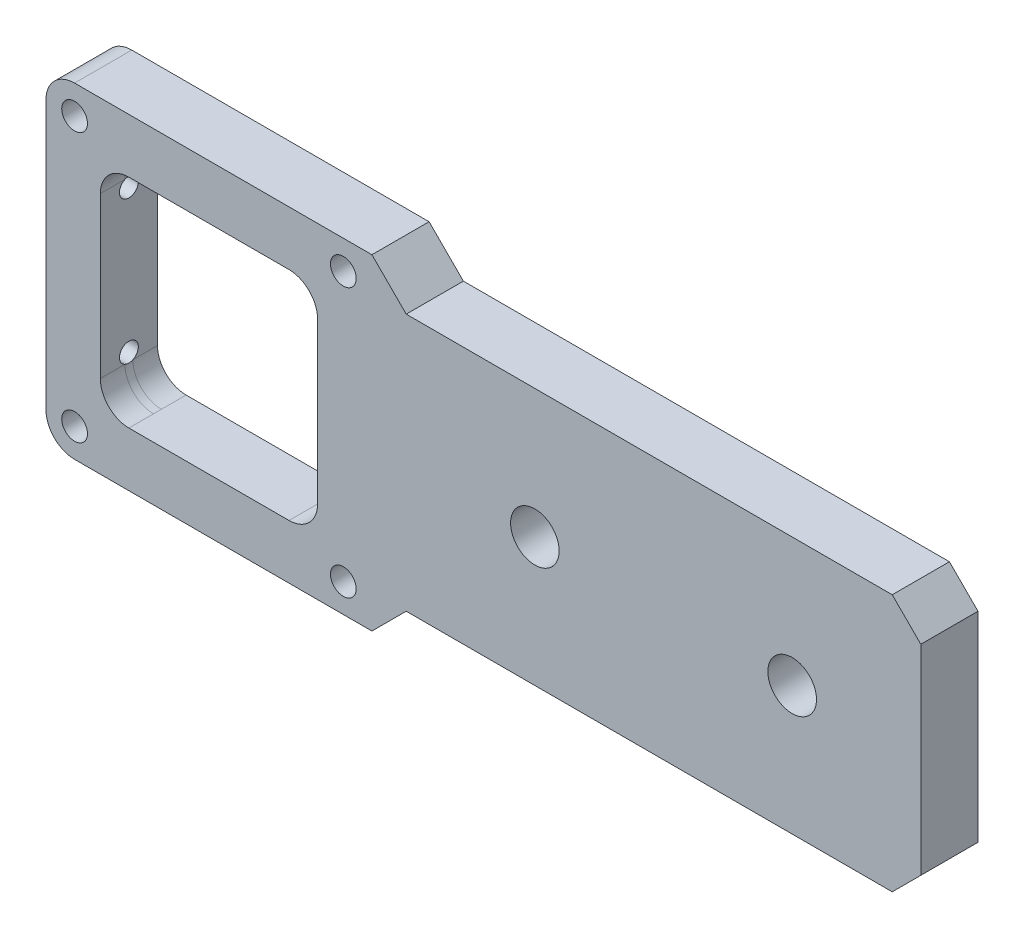
from build123d import *

# Parameters (mm, degrees)
EXTRUDE_1_DEPTH              = 5
SKETCH_6_R                   = 10
CUT_EXTRUDE_1530_DEPTH       = 10
SKETCH_19_R                  = 12
CUT_EXTRUDE_1946_DEPTH       = 5
HOLE_WIZARD_8_5_8_5_1_D      = 8.5
HOLE_WIZARD_1_D              = 4.5
HOLE_WIZARD_1_CBORE_D        = 8
HOLE_WIZARD_1_CBORE_DEPTH    = 4.6
FILLET_1_R                   = 5
CHAMFER_1_SIZE               = 5
CHAMFER_2_SIZE               = 0.2
HOLE_WIZARD_M4_1_D           = 3.3
HOLE_WIZARD_M4_1_DEPTH       = 15.5
HOLE_WIZARD_M4_1_CSINK_D     = 4.05
HOLE_WIZARD_M4_1_CSINK_ANGLE = 120
SKETCH_22_W                  = 38
SKETCH_22_H                  = 38
CUT_EXTRUDE_1_DEPTH          = 10
FILLET_2_R                   = 5


with BuildPart() as part:
    # 草图1 → 凸台-拉伸1 (new body, symmetric)
    with BuildSketch(Plane.XY):
        Polygon((28.5, 28.5), (-28.5, 28.5), (-28.5, -28.5), (28.5, -28.5), (34.5, -22.5), (124.5, -22.5), (124.5, 22.5), (34.5, 22.5), align=None)
    extrude(amount=EXTRUDE_1_DEPTH, both=True)

    # 草图6 → Cut-Extrude 1530 (cut)
    with BuildSketch(Plane.XY.offset(5)):
        Circle(SKETCH_6_R)
    extrude(amount=-CUT_EXTRUDE_1530_DEPTH, mode=Mode.SUBTRACT)

    # 草图19 → Cut-Extrude 1946 (cut)
    with BuildSketch(Plane(origin=(0, 0, -5), x_dir=(-1, 0, 0), z_dir=(0, 0, -1))):
        Circle(SKETCH_19_R)
    extrude(amount=-CUT_EXTRUDE_1946_DEPTH, mode=Mode.SUBTRACT)

    # Ø8.5 (8.5) 直径孔1 (through all)
    with Locations(Plane.XY.offset(5)):
        with Locations((57, 0), (102, 0)):
            Hole(HOLE_WIZARD_8_5_8_5_1_D / 2)

    # 打孔尺寸(%根据)内六角圆柱头螺钉的类型1 (through all)
    with Locations(Plane(origin=(0, 0, -5), x_dir=(-1, 0, 0), z_dir=(0, 0, -1))):
        with Locations((-23.5, 23.5), (23.5, 23.5), (23.5, -23.5), (-23.5, -23.5)):
            CounterBoreHole(HOLE_WIZARD_1_D / 2, HOLE_WIZARD_1_CBORE_D / 2, HOLE_WIZARD_1_CBORE_DEPTH)

    # 圆角1
    fillet_1_edges = [part.edges().sort_by_distance(p)[0] for p in [
        (-28.5, -28.5, 0),
        (-28.5, 28.5, 0),
    ]]
    fillet(fillet_1_edges, radius=FILLET_1_R)

    # 倒角1
    chamfer_1_edges = [part.edges().sort_by_distance(p)[0] for p in [
        (124.5, 22.5, 0),
        (124.5, -22.5, 0),
    ]]
    chamfer(chamfer_1_edges, length=CHAMFER_1_SIZE)

    # 倒角2
    chamfer_2_edges = [part.edges().sort_by_distance(p)[0] for p in [
        (12, 0, -5),
    ]]
    chamfer(chamfer_2_edges, length=CHAMFER_2_SIZE)

    # M4 螺纹孔1
    with Locations(Plane.ZY.offset(28.5)):
        with Locations((0, 12.5), (0, -12.5)):
            CounterSinkHole(HOLE_WIZARD_M4_1_D / 2, HOLE_WIZARD_M4_1_CSINK_D / 2, depth=HOLE_WIZARD_M4_1_DEPTH, counter_sink_angle=HOLE_WIZARD_M4_1_CSINK_ANGLE)

    # 草图22 → 切除-拉伸1 (cut)
    with BuildSketch(Plane(origin=(0, 0, -5), x_dir=(-1, 0, 0), z_dir=(0, 0, -1))):
        Rectangle(SKETCH_22_W, SKETCH_22_H)
    extrude(amount=-CUT_EXTRUDE_1_DEPTH, mode=Mode.SUBTRACT)

    # 圆角2
    fillet_2_edges = [part.edges().sort_by_distance(p)[0] for p in [
        (-19, 19, 0),
        (-19, -19, 0),
        (19, -19, 0),
        (19, 19, 0),
    ]]
    fillet(fillet_2_edges, radius=FILLET_2_R)


solid = part.part
